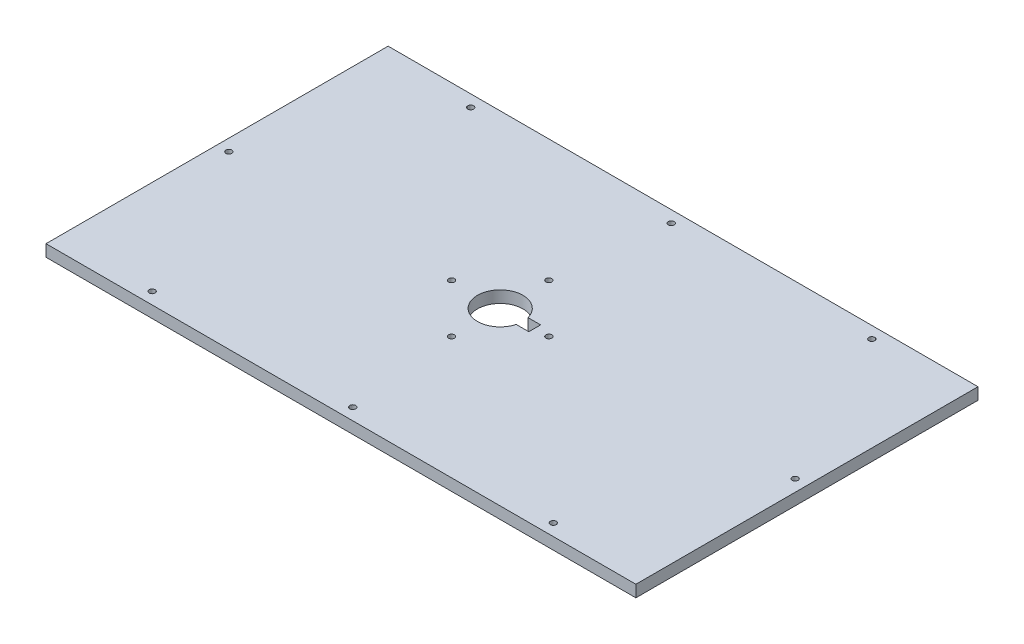
from build123d import *

# Parameters (mm, degrees)
SKETCH1_W           = 500
SKETCH1_H           = 290
SKETCH1_R           = 2.5
BOSS_EXTRUDE1_DEPTH = 10


with BuildPart() as part:
    # Sketch1 → Boss-Extrude1 (new body)
    with BuildSketch(Plane(origin=(0, 0, 0), x_dir=(1, 0, 0), z_dir=(0, 1, 0))):
        Rectangle(SKETCH1_W, SKETCH1_H)
        with Locations((-240, 0)):
            Circle(SKETCH1_R, mode=Mode.SUBTRACT)
        with Locations((-170, -135)):
            Circle(SKETCH1_R, mode=Mode.SUBTRACT)
        with Locations((-170, 135)):
            Circle(SKETCH1_R, mode=Mode.SUBTRACT)
        with Locations((170, 135)):
            Circle(SKETCH1_R, mode=Mode.SUBTRACT)
        with Locations((240, 0)):
            Circle(SKETCH1_R, mode=Mode.SUBTRACT)
        with Locations((170, -135)):
            Circle(SKETCH1_R, mode=Mode.SUBTRACT)
        with Locations((0, 135)):
            Circle(SKETCH1_R, mode=Mode.SUBTRACT)
        with Locations((0, -135)):
            Circle(SKETCH1_R, mode=Mode.SUBTRACT)
        with Locations((31.25, 0)):
            Circle(SKETCH1_R, mode=Mode.SUBTRACT)
        with Locations((-10, -41.25)):
            Circle(SKETCH1_R, mode=Mode.SUBTRACT)
        with Locations((-51.25, 0)):
            Circle(SKETCH1_R, mode=Mode.SUBTRACT)
        with Locations((-10, 41.25)):
            Circle(SKETCH1_R, mode=Mode.SUBTRACT)
        with BuildLine():
            Line((8.589311445, -5), (19.25, -5))
            Line((19.25, -5), (19.25, 5))
            Line((19.25, 5), (8.589311445, 5))
            ThreePointArc((8.589311445, 5), (-29.25, 0), (8.589311445, -5))
        make_face(mode=Mode.SUBTRACT)
    extrude(amount=BOSS_EXTRUDE1_DEPTH)


solid = part.part
